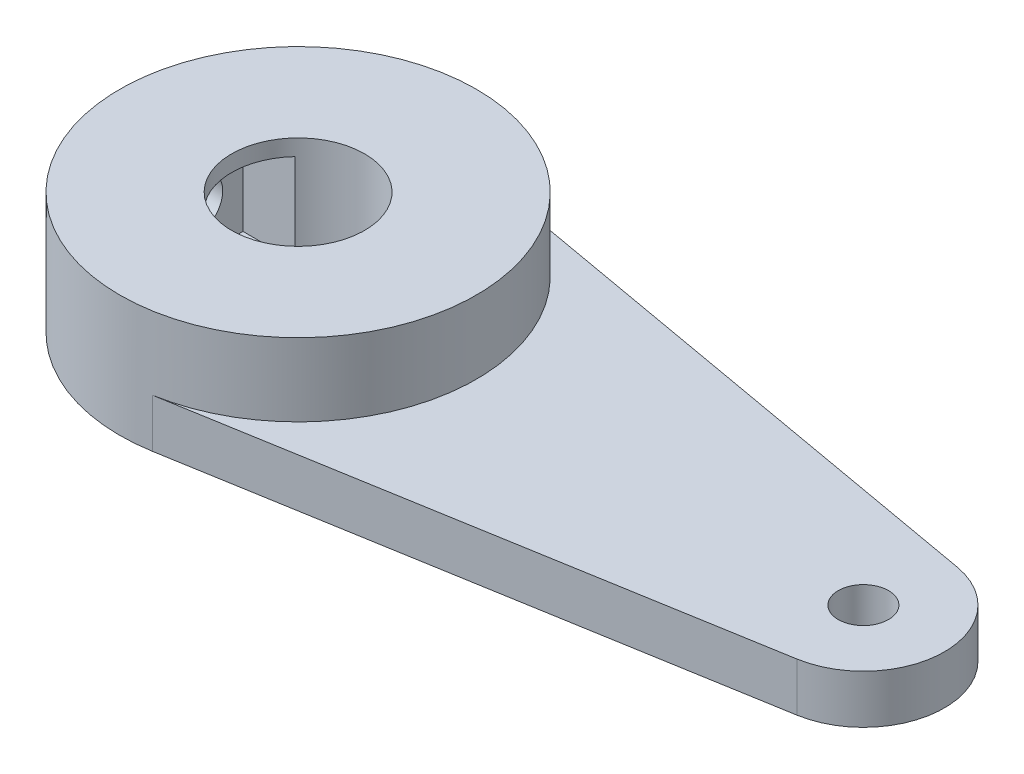
from build123d import *

# Parameters (mm, degrees)
EXTRUDE_1_DEPTH       = 3
SKETCH_4_R            = 11
EXTRUDE_2_DEPTH       = 4.5
SKETCH_5_R            = 4.1
SKETCH_5_R_2          = 1.55
CUT_EXTRUDE_1_DEPTH   = 8.5
SKETCH_7_W            = 5.6
SKETCH_7_H            = 5.6
CUT_EXTRUDE_812_DEPTH = 2.1
SKETCH_8_R            = 1.55
CUT_EXTRUDE_M3_DEPTH  = 7.9


with BuildPart() as part:
    # 草图2 → 凸台-拉伸1 (new body)
    with BuildSketch(Plane(origin=(0, 0, 0), x_dir=(1, 0, 0), z_dir=(0, 1, 0))):
        with BuildLine():
            Line((1.924560376, 10.830330898), (35.874800171, 4.797340137))
            ThreePointArc((35.874800171, 4.797340137), (39.999967838, -0.143471364), (35.839463489, -5.054563924))
            Line((35.839463489, -5.054563924), (1.846819677, -10.843858035))
            ThreePointArc((1.846819677, -10.843858035), (-10.999929243, 0.039454403), (1.924560376, 10.830330898))
        make_face()
    extrude(amount=EXTRUDE_1_DEPTH)

    # 草图4 → 凸台-拉伸2 (add)
    with BuildSketch(Plane(origin=(0, 3, 0), x_dir=(1, 0, 0), z_dir=(0, 1, 0))):
        Circle(SKETCH_4_R)
    extrude(amount=EXTRUDE_2_DEPTH)

    # 草图5 → 切除-拉伸1 (cut, through all)
    with BuildSketch(Plane.XZ):
        Circle(SKETCH_5_R)
        with Locations((35, 0.125537544)):
            Circle(SKETCH_5_R_2)
    extrude(amount=-CUT_EXTRUDE_1_DEPTH, mode=Mode.SUBTRACT)

    # 草图7 → Cut-Extrude 812 (cut, symmetric)
    with BuildSketch(Plane(origin=(-4.1, 0, 0), x_dir=(0, 0, -1), z_dir=(1, 0, 0))):
        with Locations((0, 3.7)):
            Rectangle(SKETCH_7_W, SKETCH_7_H)
    extrude(amount=CUT_EXTRUDE_812_DEPTH, both=True, mode=Mode.SUBTRACT)

    # 草图8 → 切除-M3孔 (cut, through all)
    with BuildSketch(Plane(origin=(-4.1, 0, 0), x_dir=(0, 0, -1), z_dir=(1, 0, 0))):
        with Locations((0, 3.7)):
            Circle(SKETCH_8_R)
    extrude(amount=-CUT_EXTRUDE_M3_DEPTH, mode=Mode.SUBTRACT)


solid = part.part
